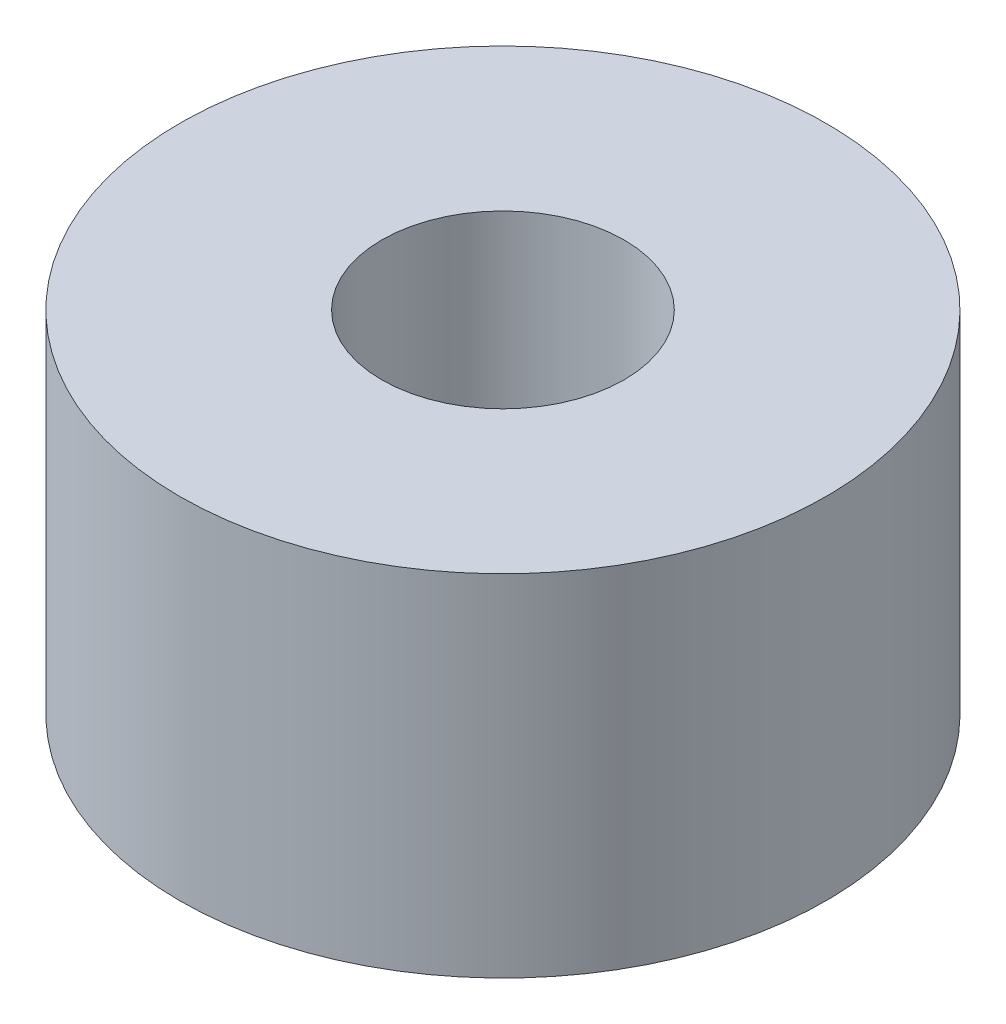
from build123d import *

# Parameters (mm, degrees)
SKETCH1_R           = 12.7
SKETCH1_R_2         = 4.7625
BOSS_EXTRUDE1_DEPTH = 13.758801286


with BuildPart() as part:
    # Sketch1 → Boss-Extrude1 (new body)
    with BuildSketch(Plane(origin=(0, 0, 0), x_dir=(1, 0, 0), z_dir=(0, 1, 0))):
        Circle(SKETCH1_R)
        Circle(SKETCH1_R_2, mode=Mode.SUBTRACT)
    extrude(amount=BOSS_EXTRUDE1_DEPTH)


solid = part.part
